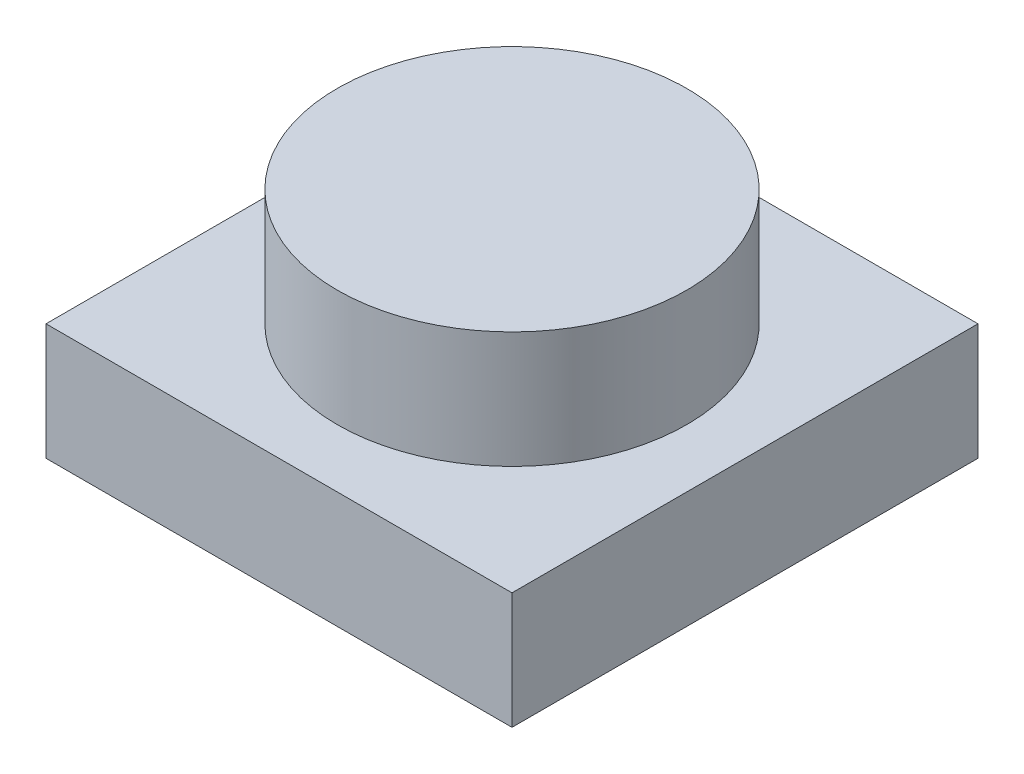
from build123d import *

# Parameters (mm, degrees)
SKETCH_1_W      = 8
SKETCH_1_H      = 8
EXTRUDE_1_DEPTH = 2
SKETCH_2_R      = 3
EXTRUDE_2_DEPTH = 2


with BuildPart() as part:
    # 草图1 → 凸台-拉伸1 (new body)
    with BuildSketch(Plane(origin=(0, 0, 0), x_dir=(1, 0, 0), z_dir=(0, 1, 0))):
        Rectangle(SKETCH_1_W, SKETCH_1_H)
    extrude(amount=EXTRUDE_1_DEPTH)

    # 草图2 → 凸台-拉伸2 (add)
    with BuildSketch(Plane(origin=(0, 2, 0), x_dir=(1, 0, 0), z_dir=(0, 1, 0))):
        Circle(SKETCH_2_R)
    extrude(amount=EXTRUDE_2_DEPTH)


solid = part.part
